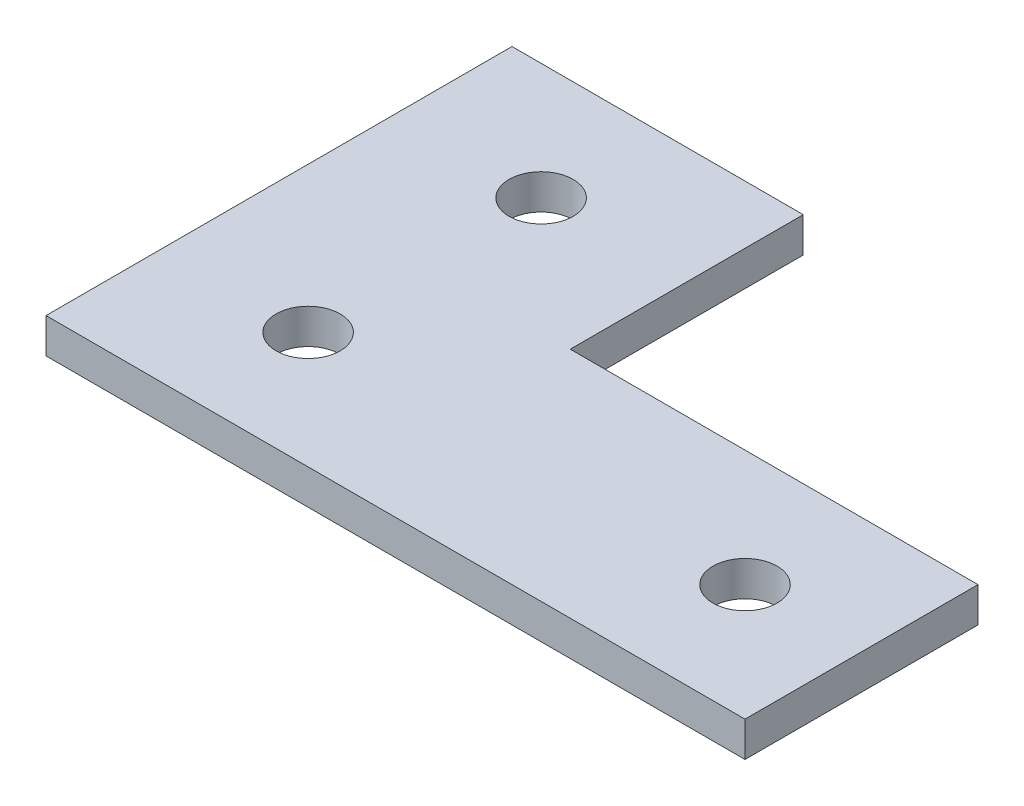
from build123d import *

# Parameters (mm, degrees)
SKETCH1_W           = 25
SKETCH1_H           = 40
SKETCH1_W_2         = 35
SKETCH1_H_2         = 20
BOSS_EXTRUDE1_DEPTH = 3
SKETCH4_R           = 2.75
CUT_EXTRUDE1_DEPTH  = 3


with BuildPart() as part:
    # Sketch1 → Boss-Extrude1 (new body)
    with BuildSketch(Plane(origin=(0, 0, 0), x_dir=(1, 0, 0), z_dir=(0, 1, 0))):
        with Locations((12.5, -20)):
            Rectangle(SKETCH1_W, SKETCH1_H)
        with Locations((42.5, -30)):
            Rectangle(SKETCH1_W_2, SKETCH1_H_2)
    extrude(amount=BOSS_EXTRUDE1_DEPTH)

    # Sketch4 → Cut-Extrude1 (cut)
    with BuildSketch(Plane(origin=(0, 3, 0), x_dir=(1, 0, 0), z_dir=(0, 1, 0))):
        with Locations((12.5, -10)):
            Circle(SKETCH4_R)
        with Locations((12.5, -30)):
            Circle(SKETCH4_R)
        with Locations((50, -30)):
            Circle(SKETCH4_R)
    extrude(amount=-CUT_EXTRUDE1_DEPTH, mode=Mode.SUBTRACT)


solid = part.part
